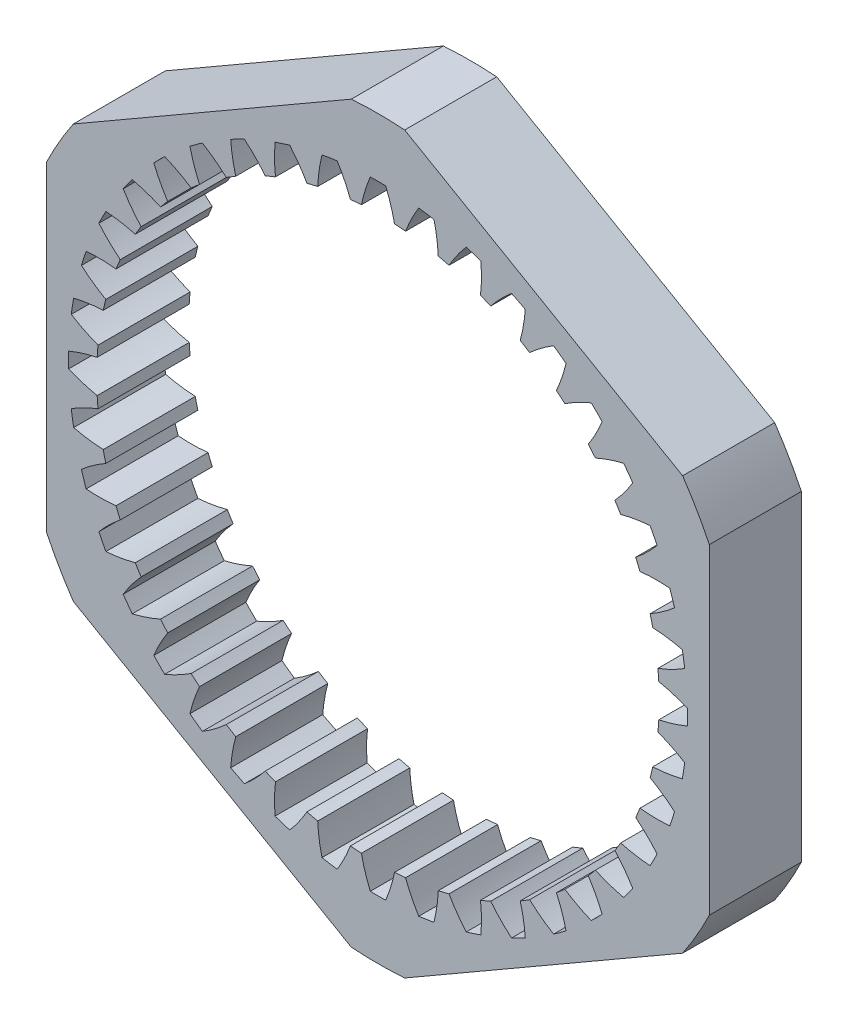
from build123d import *

# Parameters (mm, degrees)
BOSS_EXTRUDE1_DEPTH = 7.9375


with BuildPart() as part:
    # Sketch1 → Boss-Extrude1 (new body)
    with BuildSketch(Plane(origin=(0, 0, -7.9375), x_dir=(-1, 0, 0), z_dir=(0, 0, -1))):
        with BuildLine():
            Line((-28.575, 13.839504146), (-28.575, -13.839504146))
            ThreePointArc((-28.575, -13.839504146), (-27.49630657, -15.875), (-26.272862166, -17.82692384))
            Line((-26.272862166, -17.82692384), (-2.302137834, -31.666427986))
            ThreePointArc((-2.302137834, -31.666427986), (0, -31.75), (2.302137834, -31.666427986))
            Line((2.302137834, -31.666427986), (26.272862166, -17.82692384))
            ThreePointArc((26.272862166, -17.82692384), (27.49630657, -15.875), (28.575, -13.839504146))
            Line((28.575, -13.839504146), (28.575, 13.839504146))
            ThreePointArc((28.575, 13.839504146), (27.49630657, 15.875), (26.272862166, 17.82692384))
            Line((26.272862166, 17.82692384), (2.302137834, 31.666427986))
            ThreePointArc((2.302137834, 31.666427986), (0, 31.75), (-2.302137834, 31.666427986))
            Line((-2.302137834, 31.666427986), (-26.272862166, 17.82692384))
            ThreePointArc((-26.272862166, 17.82692384), (-27.49630657, 15.875), (-28.575, 13.839504146))
        make_face()
        with BuildLine():
            ThreePointArc((8.840960916, -22.588480672), (8.920352857, -23.87526969), (8.874420221, -25.163687032))
            ThreePointArc((8.874420221, -25.163687032), (8.245407756, -25.376755707), (7.611287357, -25.574103778))
            ThreePointArc((7.611287357, -25.574103778), (6.816814361, -24.558750779), (6.124688184, -23.471051183))
            ThreePointArc((6.124688184, -23.471051183), (5.662684191, -23.586777159), (5.198497126, -23.693409983))
            ThreePointArc((5.198497126, -23.693409983), (5.075613469, -24.976776128), (4.828693462, -26.242145468))
            ThreePointArc((4.828693462, -26.242145468), (4.1740939, -26.354191686), (3.516908536, -26.449911789))
            ThreePointArc((3.516908536, -26.449911789), (2.891053024, -25.322776511), (2.377601773, -24.140195915))
            ThreePointArc((2.377601773, -24.140195915), (1.903182285, -24.182223764), (1.428029084, -24.214928906))
            ThreePointArc((1.428029084, -24.214928906), (1.105895633, -25.463271445), (0.664068245, -26.674435189))
            ThreePointArc((0.664068245, -26.674435189), (0, -26.6827), (-0.664068245, -26.674435189))
            ThreePointArc((-0.664068245, -26.674435189), (-1.105895633, -25.463271445), (-1.428029084, -24.214928906))
            ThreePointArc((-1.428029084, -24.214928906), (-1.903182285, -24.182223764), (-2.377601773, -24.140195915))
            ThreePointArc((-2.377601773, -24.140195915), (-2.891053024, -25.322776511), (-3.516908536, -26.449911789))
            ThreePointArc((-3.516908536, -26.449911789), (-4.1740939, -26.354191686), (-4.828693462, -26.242145468))
            ThreePointArc((-4.828693462, -26.242145468), (-5.075613469, -24.976776128), (-5.198497126, -23.693409983))
            ThreePointArc((-5.198497126, -23.693409983), (-5.662684191, -23.586777159), (-6.124688184, -23.471051183))
            ThreePointArc((-6.124688184, -23.471051183), (-6.816814361, -24.558750779), (-7.611287357, -25.574103778))
            ThreePointArc((-7.611287357, -25.574103778), (-8.245407756, -25.376755707), (-8.874420221, -25.163687032))
            ThreePointArc((-8.874420221, -25.163687032), (-8.920352857, -23.87526969), (-8.840960916, -22.588480672))
            ThreePointArc((-8.840960916, -22.588480672), (-9.282752019, -22.41054582), (-9.720964445, -22.223971276))
            ThreePointArc((-9.720964445, -22.223971276), (-10.574723105, -23.190007096), (-11.518251023, -24.068576457))
            ThreePointArc((-11.518251023, -24.068576457), (-12.113692307, -23.774459783), (-12.701629301, -23.465615108))
            ThreePointArc((-12.701629301, -23.465615108), (-12.545443552, -22.185874874), (-12.265730906, -20.927348001))
            ThreePointArc((-12.265730906, -20.927348001), (-12.674247684, -20.682492467), (-13.077878299, -20.429663438))
            ThreePointArc((-13.077878299, -20.429663438), (-14.07224707, -21.250248475), (-15.141597122, -21.970400904))
            ThreePointArc((-15.141597122, -21.970400904), (-15.683697551, -21.586757756), (-16.216082113, -21.189741862))
            ThreePointArc((-16.216082113, -21.189741862), (-15.861623791, -19.950190188), (-15.388477894, -18.750914567))
            ThreePointArc((-15.388477894, -18.750914567), (-15.753661308, -18.445167508), (-16.112771386, -18.132309485))
            ThreePointArc((-16.112771386, -18.132309485), (-17.223265609, -18.787238211), (-18.392106847, -19.331241166))
            ThreePointArc((-18.392106847, -19.331241166), (-18.86751811, -18.86751811), (-19.331241166, -18.392106847))
            ThreePointArc((-19.331241166, -18.392106847), (-18.787238211, -17.223265609), (-18.132309485, -16.112771386))
            ThreePointArc((-18.132309485, -16.112771386), (-18.445167508, -15.753661308), (-18.750914567, -15.388477894))
            ThreePointArc((-18.750914567, -15.388477894), (-19.950190188, -15.861623791), (-21.189741862, -16.216082113))
            ThreePointArc((-21.189741862, -16.216082113), (-21.586757756, -15.683697551), (-21.970400904, -15.141597122))
            ThreePointArc((-21.970400904, -15.141597122), (-21.250248475, -14.07224707), (-20.429663438, -13.077878299))
            ThreePointArc((-20.429663438, -13.077878299), (-20.682492467, -12.674247684), (-20.927348001, -12.265730906))
            ThreePointArc((-20.927348001, -12.265730906), (-22.185874874, -12.545443552), (-23.465615108, -12.701629301))
            ThreePointArc((-23.465615108, -12.701629301), (-23.774459783, -12.113692307), (-24.068576457, -11.518251023))
            ThreePointArc((-24.068576457, -11.518251023), (-23.190007096, -10.574723105), (-22.223971276, -9.720964445))
            ThreePointArc((-22.223971276, -9.720964445), (-22.41054582, -9.282752019), (-22.588480672, -8.840960916))
            ThreePointArc((-22.588480672, -8.840960916), (-23.87526969, -8.920352857), (-25.163687032, -8.874420221))
            ThreePointArc((-25.163687032, -8.874420221), (-25.376755707, -8.245407756), (-25.574103778, -7.611287357))
            ThreePointArc((-25.574103778, -7.611287357), (-24.558750779, -6.816814361), (-23.471051183, -6.124688184))
            ThreePointArc((-23.471051183, -6.124688184), (-23.586777159, -5.662684191), (-23.693409983, -5.198497126))
            ThreePointArc((-23.693409983, -5.198497126), (-24.976776128, -5.075613469), (-26.242145468, -4.828693462))
            ThreePointArc((-26.242145468, -4.828693462), (-26.354191686, -4.1740939), (-26.449911789, -3.516908536))
            ThreePointArc((-26.449911789, -3.516908536), (-25.322776511, -2.891053024), (-24.140195915, -2.377601773))
            ThreePointArc((-24.140195915, -2.377601773), (-24.182223764, -1.903182285), (-24.214928906, -1.428029084))
            ThreePointArc((-24.214928906, -1.428029084), (-25.463271445, -1.105895633), (-26.674435189, -0.664068245))
            ThreePointArc((-26.674435189, -0.664068245), (-26.6827, 0), (-26.674435189, 0.664068245))
            ThreePointArc((-26.674435189, 0.664068245), (-25.463271445, 1.105895633), (-24.214928906, 1.428029084))
            ThreePointArc((-24.214928906, 1.428029084), (-24.182223764, 1.903182285), (-24.140195915, 2.377601773))
            ThreePointArc((-24.140195915, 2.377601773), (-25.322776511, 2.891053024), (-26.449911789, 3.516908536))
            ThreePointArc((-26.449911789, 3.516908536), (-26.354191686, 4.1740939), (-26.242145468, 4.828693462))
            ThreePointArc((-26.242145468, 4.828693462), (-24.976776128, 5.075613469), (-23.693409983, 5.198497126))
            ThreePointArc((-23.693409983, 5.198497126), (-23.586777159, 5.662684191), (-23.471051183, 6.124688184))
            ThreePointArc((-23.471051183, 6.124688184), (-24.558750779, 6.816814361), (-25.574103778, 7.611287357))
            ThreePointArc((-25.574103778, 7.611287357), (-25.376755707, 8.245407756), (-25.163687032, 8.874420221))
            ThreePointArc((-25.163687032, 8.874420221), (-23.87526969, 8.920352857), (-22.588480672, 8.840960916))
            ThreePointArc((-22.588480672, 8.840960916), (-22.41054582, 9.282752019), (-22.223971276, 9.720964445))
            ThreePointArc((-22.223971276, 9.720964445), (-23.190007096, 10.574723105), (-24.068576457, 11.518251023))
            ThreePointArc((-24.068576457, 11.518251023), (-23.774459783, 12.113692307), (-23.465615108, 12.701629301))
            ThreePointArc((-23.465615108, 12.701629301), (-22.185874874, 12.545443552), (-20.927348001, 12.265730906))
            ThreePointArc((-20.927348001, 12.265730906), (-20.682492467, 12.674247684), (-20.429663438, 13.077878299))
            ThreePointArc((-20.429663438, 13.077878299), (-21.250248475, 14.07224707), (-21.970400904, 15.141597122))
            ThreePointArc((-21.970400904, 15.141597122), (-21.586757756, 15.683697551), (-21.189741862, 16.216082113))
            ThreePointArc((-21.189741862, 16.216082113), (-19.950190188, 15.861623791), (-18.750914567, 15.388477894))
            ThreePointArc((-18.750914567, 15.388477894), (-18.445167508, 15.753661308), (-18.132309485, 16.112771386))
            ThreePointArc((-18.132309485, 16.112771386), (-18.787238211, 17.223265609), (-19.331241166, 18.392106847))
            ThreePointArc((-19.331241166, 18.392106847), (-18.86751811, 18.86751811), (-18.392106847, 19.331241166))
            ThreePointArc((-18.392106847, 19.331241166), (-17.223265609, 18.787238211), (-16.112771386, 18.132309485))
            ThreePointArc((-16.112771386, 18.132309485), (-15.753661308, 18.445167508), (-15.388477894, 18.750914567))
            ThreePointArc((-15.388477894, 18.750914567), (-15.861623791, 19.950190188), (-16.216082113, 21.189741862))
            ThreePointArc((-16.216082113, 21.189741862), (-15.683697551, 21.586757756), (-15.141597122, 21.970400904))
            ThreePointArc((-15.141597122, 21.970400904), (-14.07224707, 21.250248475), (-13.077878299, 20.429663438))
            ThreePointArc((-13.077878299, 20.429663438), (-12.674247684, 20.682492467), (-12.265730906, 20.927348001))
            ThreePointArc((-12.265730906, 20.927348001), (-12.545443552, 22.185874874), (-12.701629301, 23.465615108))
            ThreePointArc((-12.701629301, 23.465615108), (-12.113692307, 23.774459783), (-11.518251023, 24.068576457))
            ThreePointArc((-11.518251023, 24.068576457), (-10.574723105, 23.190007096), (-9.720964445, 22.223971276))
            ThreePointArc((-9.720964445, 22.223971276), (-9.282752019, 22.41054582), (-8.840960916, 22.588480672))
            ThreePointArc((-8.840960916, 22.588480672), (-8.920352857, 23.87526969), (-8.874420221, 25.163687032))
            ThreePointArc((-8.874420221, 25.163687032), (-8.245407756, 25.376755707), (-7.611287357, 25.574103778))
            ThreePointArc((-7.611287357, 25.574103778), (-6.816814361, 24.558750779), (-6.124688184, 23.471051183))
            ThreePointArc((-6.124688184, 23.471051183), (-5.662684191, 23.586777159), (-5.198497126, 23.693409983))
            ThreePointArc((-5.198497126, 23.693409983), (-5.075613469, 24.976776128), (-4.828693462, 26.242145468))
            ThreePointArc((-4.828693462, 26.242145468), (-4.1740939, 26.354191686), (-3.516908536, 26.449911789))
            ThreePointArc((-3.516908536, 26.449911789), (-2.891053024, 25.322776511), (-2.377601773, 24.140195915))
            ThreePointArc((-2.377601773, 24.140195915), (-1.903182285, 24.182223764), (-1.428029084, 24.214928906))
            ThreePointArc((-1.428029084, 24.214928906), (-1.105895633, 25.463271445), (-0.664068245, 26.674435189))
            ThreePointArc((-0.664068245, 26.674435189), (0, 26.6827), (0.664068245, 26.674435189))
            ThreePointArc((0.664068245, 26.674435189), (1.105895633, 25.463271445), (1.428029084, 24.214928906))
            ThreePointArc((1.428029084, 24.214928906), (1.903182285, 24.182223764), (2.377601773, 24.140195915))
            ThreePointArc((2.377601773, 24.140195915), (2.891053024, 25.322776511), (3.516908536, 26.449911789))
            ThreePointArc((3.516908536, 26.449911789), (4.1740939, 26.354191686), (4.828693462, 26.242145468))
            ThreePointArc((4.828693462, 26.242145468), (5.075613469, 24.976776128), (5.198497126, 23.693409983))
            ThreePointArc((5.198497126, 23.693409983), (5.662684191, 23.586777159), (6.124688184, 23.471051183))
            ThreePointArc((6.124688184, 23.471051183), (6.816814361, 24.558750779), (7.611287357, 25.574103778))
            ThreePointArc((7.611287357, 25.574103778), (8.245407756, 25.376755707), (8.874420221, 25.163687032))
            ThreePointArc((8.874420221, 25.163687032), (8.920352857, 23.87526969), (8.840960916, 22.588480672))
            ThreePointArc((8.840960916, 22.588480672), (9.282752019, 22.41054582), (9.720964445, 22.223971276))
            ThreePointArc((9.720964445, 22.223971276), (10.574723105, 23.190007096), (11.518251023, 24.068576457))
            ThreePointArc((11.518251023, 24.068576457), (12.113692307, 23.774459783), (12.701629301, 23.465615108))
            ThreePointArc((12.701629301, 23.465615108), (12.545443552, 22.185874874), (12.265730906, 20.927348001))
            ThreePointArc((12.265730906, 20.927348001), (12.674247684, 20.682492467), (13.077878299, 20.429663438))
            ThreePointArc((13.077878299, 20.429663438), (14.07224707, 21.250248475), (15.141597122, 21.970400904))
            ThreePointArc((15.141597122, 21.970400904), (15.683697551, 21.586757756), (16.216082113, 21.189741862))
            ThreePointArc((16.216082113, 21.189741862), (15.861623791, 19.950190188), (15.388477894, 18.750914567))
            ThreePointArc((15.388477894, 18.750914567), (15.753661308, 18.445167508), (16.112771386, 18.132309485))
            ThreePointArc((16.112771386, 18.132309485), (17.223265609, 18.787238211), (18.392106847, 19.331241166))
            ThreePointArc((18.392106847, 19.331241166), (18.86751811, 18.86751811), (19.331241166, 18.392106847))
            ThreePointArc((19.331241166, 18.392106847), (18.787238211, 17.223265609), (18.132309485, 16.112771386))
            ThreePointArc((18.132309485, 16.112771386), (18.445167508, 15.753661308), (18.750914567, 15.388477894))
            ThreePointArc((18.750914567, 15.388477894), (19.950190188, 15.861623791), (21.189741862, 16.216082113))
            ThreePointArc((21.189741862, 16.216082113), (21.586757756, 15.683697551), (21.970400904, 15.141597122))
            ThreePointArc((21.970400904, 15.141597122), (21.250248475, 14.07224707), (20.429663438, 13.077878299))
            ThreePointArc((20.429663438, 13.077878299), (20.682492467, 12.674247684), (20.927348001, 12.265730906))
            ThreePointArc((20.927348001, 12.265730906), (22.185874874, 12.545443552), (23.465615108, 12.701629301))
            ThreePointArc((23.465615108, 12.701629301), (23.774459783, 12.113692307), (24.068576457, 11.518251023))
            ThreePointArc((24.068576457, 11.518251023), (23.190007096, 10.574723105), (22.223971276, 9.720964445))
            ThreePointArc((22.223971276, 9.720964445), (22.41054582, 9.282752019), (22.588480672, 8.840960916))
            ThreePointArc((22.588480672, 8.840960916), (23.87526969, 8.920352857), (25.163687032, 8.874420221))
            ThreePointArc((25.163687032, 8.874420221), (25.376755707, 8.245407756), (25.574103778, 7.611287357))
            ThreePointArc((25.574103778, 7.611287357), (24.558750779, 6.816814361), (23.471051183, 6.124688184))
            ThreePointArc((23.471051183, 6.124688184), (23.586777159, 5.662684191), (23.693409983, 5.198497126))
            ThreePointArc((23.693409983, 5.198497126), (24.976776128, 5.075613469), (26.242145468, 4.828693462))
            ThreePointArc((26.242145468, 4.828693462), (26.354191686, 4.1740939), (26.449911789, 3.516908536))
            ThreePointArc((26.449911789, 3.516908536), (25.322776511, 2.891053024), (24.140195915, 2.377601773))
            ThreePointArc((24.140195915, 2.377601773), (24.182223764, 1.903182285), (24.214928906, 1.428029084))
            ThreePointArc((24.214928906, 1.428029084), (25.463271445, 1.105895633), (26.674435189, 0.664068245))
            ThreePointArc((26.674435189, 0.664068245), (26.6827, 0), (26.674435189, -0.664068245))
            ThreePointArc((26.674435189, -0.664068245), (25.463271445, -1.105895633), (24.214928906, -1.428029084))
            ThreePointArc((24.214928906, -1.428029084), (24.182223764, -1.903182285), (24.140195915, -2.377601773))
            ThreePointArc((24.140195915, -2.377601773), (25.322776511, -2.891053024), (26.449911789, -3.516908536))
            ThreePointArc((26.449911789, -3.516908536), (26.354191686, -4.1740939), (26.242145468, -4.828693462))
            ThreePointArc((26.242145468, -4.828693462), (24.976776128, -5.075613469), (23.693409983, -5.198497126))
            ThreePointArc((23.693409983, -5.198497126), (23.586777159, -5.662684191), (23.471051183, -6.124688184))
            ThreePointArc((23.471051183, -6.124688184), (24.558750779, -6.816814361), (25.574103778, -7.611287357))
            ThreePointArc((25.574103778, -7.611287357), (25.376755707, -8.245407756), (25.163687032, -8.874420221))
            ThreePointArc((25.163687032, -8.874420221), (23.87526969, -8.920352857), (22.588480672, -8.840960916))
            ThreePointArc((22.588480672, -8.840960916), (22.41054582, -9.282752019), (22.223971276, -9.720964445))
            ThreePointArc((22.223971276, -9.720964445), (23.190007096, -10.574723105), (24.068576457, -11.518251023))
            ThreePointArc((24.068576457, -11.518251023), (23.774459783, -12.113692307), (23.465615108, -12.701629301))
            ThreePointArc((23.465615108, -12.701629301), (22.185874874, -12.545443552), (20.927348001, -12.265730906))
            ThreePointArc((20.927348001, -12.265730906), (20.682492467, -12.674247684), (20.429663438, -13.077878299))
            ThreePointArc((20.429663438, -13.077878299), (21.250248475, -14.07224707), (21.970400904, -15.141597122))
            ThreePointArc((21.970400904, -15.141597122), (21.586757756, -15.683697551), (21.189741862, -16.216082113))
            ThreePointArc((21.189741862, -16.216082113), (19.950190188, -15.861623791), (18.750914567, -15.388477894))
            ThreePointArc((18.750914567, -15.388477894), (18.445167508, -15.753661308), (18.132309485, -16.112771386))
            ThreePointArc((18.132309485, -16.112771386), (18.787238211, -17.223265609), (19.331241166, -18.392106847))
            ThreePointArc((19.331241166, -18.392106847), (18.86751811, -18.86751811), (18.392106847, -19.331241166))
            ThreePointArc((18.392106847, -19.331241166), (17.223265609, -18.787238211), (16.112771386, -18.132309485))
            ThreePointArc((16.112771386, -18.132309485), (15.753661308, -18.445167508), (15.388477894, -18.750914567))
            ThreePointArc((15.388477894, -18.750914567), (15.861623791, -19.950190188), (16.216082113, -21.189741862))
            ThreePointArc((16.216082113, -21.189741862), (15.683697551, -21.586757756), (15.141597122, -21.970400904))
            ThreePointArc((15.141597122, -21.970400904), (14.07224707, -21.250248475), (13.077878299, -20.429663438))
            ThreePointArc((13.077878299, -20.429663438), (12.674247684, -20.682492467), (12.265730906, -20.927348001))
            ThreePointArc((12.265730906, -20.927348001), (12.545443552, -22.185874874), (12.701629301, -23.465615108))
            ThreePointArc((12.701629301, -23.465615108), (12.113692307, -23.774459783), (11.518251023, -24.068576457))
            ThreePointArc((11.518251023, -24.068576457), (10.574723105, -23.190007096), (9.720964445, -22.223971276))
            ThreePointArc((9.720964445, -22.223971276), (9.282752019, -22.41054582), (8.840960916, -22.588480672))
        make_face(mode=Mode.SUBTRACT)
    extrude(amount=-BOSS_EXTRUDE1_DEPTH)


solid = part.part
